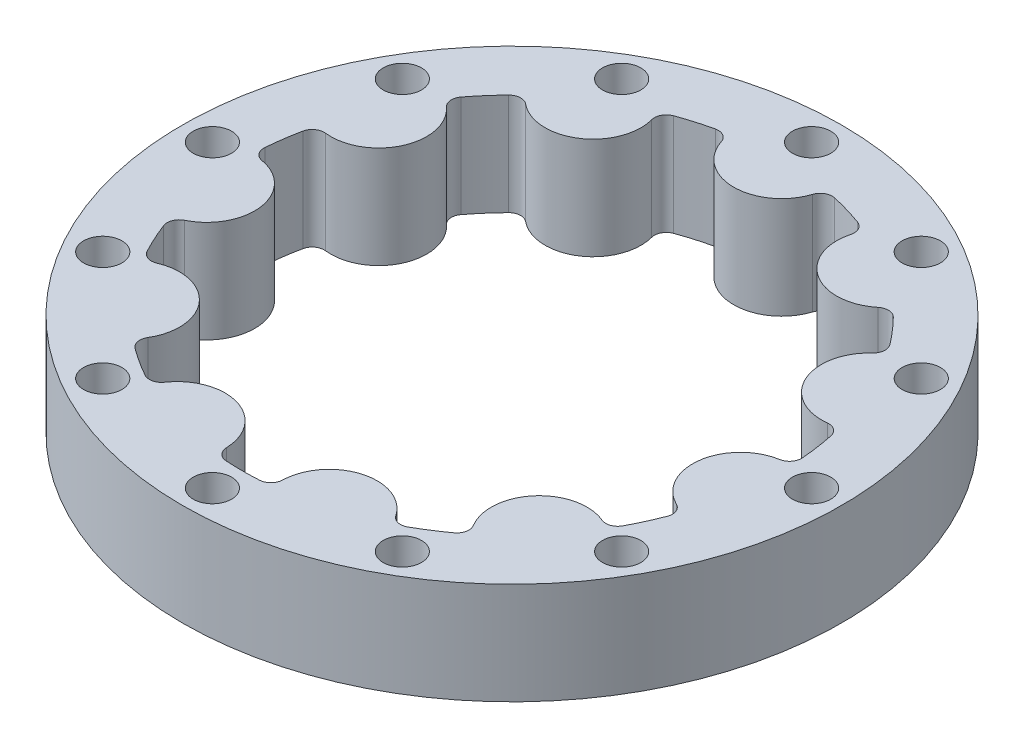
from build123d import *

# Parameters (mm, degrees)
SKETCH1_R           = 27.5
BOSS_EXTRUDE2_DEPTH = 8.5
FILLET2_R           = 1
SKETCH2_R           = 1.6
CUT_EXTRUDE1_DEPTH  = 10


with BuildPart() as part:
    # Sketch1 → Boss-Extrude2 (new body)
    with BuildSketch(Plane(origin=(0, 0, 0), x_dir=(1, 0, 0), z_dir=(0, 1, 0))):
        Circle(SKETCH1_R)
        with BuildLine():
            ThreePointArc((22.486051897, 0.792130095), (18.311696675, -2.632824508), (21.352039962, -7.095096155))
            ThreePointArc((21.352039962, -7.095096155), (20.466719895, -9.346837793), (19.34472846, -11.490495238))
            ThreePointArc((19.34472846, -11.490495238), (13.981367126, -12.114923578), (14.126580466, -17.512559046))
            ThreePointArc((14.126580466, -17.512559046), (12.164418393, -18.928204489), (10.06159042, -20.124969521))
            ThreePointArc((10.06159042, -20.124969521), (5.212052302, -17.750620012), (2.416031486, -22.369908177))
            ThreePointArc((2.416031486, -22.369908177), (0, -22.5), (-2.416031486, -22.369908177))
            ThreePointArc((-2.416031486, -22.369908177), (-5.212052302, -17.750620012), (-10.06159042, -20.124969521))
            ThreePointArc((-10.06159042, -20.124969521), (-12.164418393, -18.928204489), (-14.126580466, -17.512559046))
            ThreePointArc((-14.126580466, -17.512559046), (-13.981367126, -12.114923578), (-19.34472846, -11.490495238))
            ThreePointArc((-19.34472846, -11.490495238), (-20.466719895, -9.346837793), (-21.352039962, -7.095096155))
            ThreePointArc((-21.352039962, -7.095096155), (-18.311696675, -2.632824508), (-22.486051897, 0.792130095))
            ThreePointArc((-22.486051897, 0.792130095), (-22.270982442, 3.202083861), (-21.798377637, 5.575009634))
            ThreePointArc((-21.798377637, 5.575009634), (-16.828191914, 7.685177741), (-18.488212735, 12.82325972))
            ThreePointArc((-18.488212735, 12.82325972), (-17.004365423, 14.734366514), (-15.323884431, 16.475089254))
            ThreePointArc((-15.323884431, 16.475089254), (-10.001855123, 15.563190357), (-8.620496662, 20.783094988))
            ThreePointArc((-8.620496662, 20.783094988), (-6.338982529, 21.588591906), (-3.984166192, 22.144444444))
            ThreePointArc((-3.984166192, 22.144444444), (0, 18.5), (3.984166192, 22.144444444))
            ThreePointArc((3.984166192, 22.144444444), (6.338982529, 21.588591906), (8.620496662, 20.783094988))
            ThreePointArc((8.620496662, 20.783094988), (10.001855123, 15.563190357), (15.323884431, 16.475089254))
            ThreePointArc((15.323884431, 16.475089254), (17.004365423, 14.734366514), (18.488212735, 12.82325972))
            ThreePointArc((18.488212735, 12.82325972), (16.828191914, 7.685177741), (21.798377637, 5.575009634))
            ThreePointArc((21.798377637, 5.575009634), (22.270982442, 3.202083861), (22.486051897, 0.792130095))
        make_face(mode=Mode.SUBTRACT)
    extrude(amount=BOSS_EXTRUDE2_DEPTH)

    # Fillet2
    fillet2_edges = [part.edges().sort_by_distance(p)[0] for p in [
        (-18.488212735, 4.25, -12.82325972),
        (-21.798377637, 4.25, -5.575009634),
        (-22.486051897, 4.25, -0.792130095),
        (-21.352039962, 4.25, 7.095096155),
        (-19.34472846, 4.25, 11.490495238),
        (-14.126580466, 4.25, 17.512559046),
        (-10.06159042, 4.25, 20.124969521),
        (-2.416031486, 4.25, 22.369908177),
        (2.416031486, 4.25, 22.369908177),
        (10.06159042, 4.25, 20.124969521),
        (14.126580466, 4.25, 17.512559046),
        (19.34472846, 4.25, 11.490495238),
        (21.352039962, 4.25, 7.095096155),
        (22.486051897, 4.25, -0.792130095),
        (21.798377637, 4.25, -5.575009634),
        (18.488212735, 4.25, -12.82325972),
        (15.323884431, 4.25, -16.475089254),
        (8.620496662, 4.25, -20.783094988),
        (3.984166192, 4.25, -22.144444444),
        (-3.984166192, 4.25, -22.144444444),
        (-8.620496662, 4.25, -20.783094988),
        (-15.323884431, 4.25, -16.475089254),
    ]]
    fillet(fillet2_edges, radius=FILLET2_R)

    # Sketch2 → Cut-Extrude1 (cut)
    with BuildSketch(Plane.XZ):
        with Locations((25, 0)):
            Circle(SKETCH2_R)
        with Locations((21.650635095, -12.5)):
            Circle(SKETCH2_R)
        with Locations((12.5, -21.650635095)):
            Circle(SKETCH2_R)
        with Locations((0, -25)):
            Circle(SKETCH2_R)
        with Locations((-12.5, -21.650635095)):
            Circle(SKETCH2_R)
        with Locations((-21.650635095, -12.5)):
            Circle(SKETCH2_R)
        with Locations((-25, 0)):
            Circle(SKETCH2_R)
        with Locations((-21.650635095, 12.5)):
            Circle(SKETCH2_R)
        with Locations((-12.5, 21.650635095)):
            Circle(SKETCH2_R)
        with Locations((0, 25)):
            Circle(SKETCH2_R)
        with Locations((12.5, 21.650635095)):
            Circle(SKETCH2_R)
        with Locations((21.650635095, 12.5)):
            Circle(SKETCH2_R)
    extrude(amount=-CUT_EXTRUDE1_DEPTH, mode=Mode.SUBTRACT)


solid = part.part
